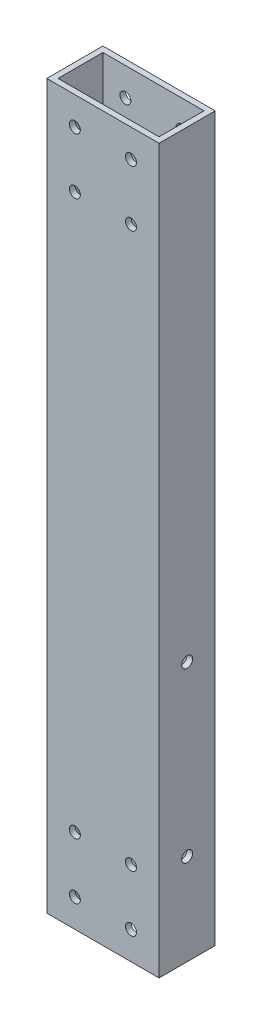
from build123d import *

# Parameters (mm, degrees)
SKETCH1_W               = 50.8
SKETCH1_H               = 25.4
SKETCH1_W_2             = 45.72
SKETCH1_H_2             = 20.32
EXTRUDE_THIN1_DEPTH     = 163.5125
SKETCH3_R               = 2.4765
CUT_EXTRUDE2_DEPTH      = 13.7
CUT_EXTRUDE2_DEPTH_BACK = 13.7
SKETCH4_R               = 2.4765
CUT_EXTRUDE3_DEPTH      = 2.54


with BuildPart() as part:
    # Sketch1 → Extrude-Thin1 (new body, symmetric)
    with BuildSketch(Plane(origin=(0, 0, 0), x_dir=(1, 0, 0), z_dir=(0, 1, 0))):
        Rectangle(SKETCH1_W, SKETCH1_H)
        Rectangle(SKETCH1_W_2, SKETCH1_H_2, mode=Mode.SUBTRACT)
    extrude(amount=EXTRUDE_THIN1_DEPTH, both=True)

    # Sketch3 → Cut-Extrude2 (cut, two sides)
    with BuildSketch(Plane.XY) as cut_extrude2_sk:
        with Locations((-12.7, -125.4125)):
            Circle(SKETCH3_R)
        with Locations((12.7, -125.4125)):
            Circle(SKETCH3_R)
        with Locations((12.7, -150.8125)):
            Circle(SKETCH3_R)
        with Locations((-12.7, -150.8125)):
            Circle(SKETCH3_R)
        with Locations((12.7, 150.8125)):
            Circle(SKETCH3_R)
        with Locations((12.7, 125.4125)):
            Circle(SKETCH3_R)
        with Locations((-12.7, 125.4125)):
            Circle(SKETCH3_R)
        with Locations((-12.7, 150.8125)):
            Circle(SKETCH3_R)
    extrude(amount=CUT_EXTRUDE2_DEPTH, mode=Mode.SUBTRACT)
    extrude(cut_extrude2_sk.sketch, amount=-CUT_EXTRUDE2_DEPTH_BACK, mode=Mode.SUBTRACT)

    # Sketch4 → Cut-Extrude3 (cut)
    with BuildSketch(Plane(origin=(25.4, 0, 0), x_dir=(0, 0, -1), z_dir=(1, 0, 0))):
        with Locations((0, -46.0375)):
            Circle(SKETCH4_R)
        with Locations((0, -122.2375)):
            Circle(SKETCH4_R)
    extrude(amount=-CUT_EXTRUDE3_DEPTH, mode=Mode.SUBTRACT)


solid = part.part
